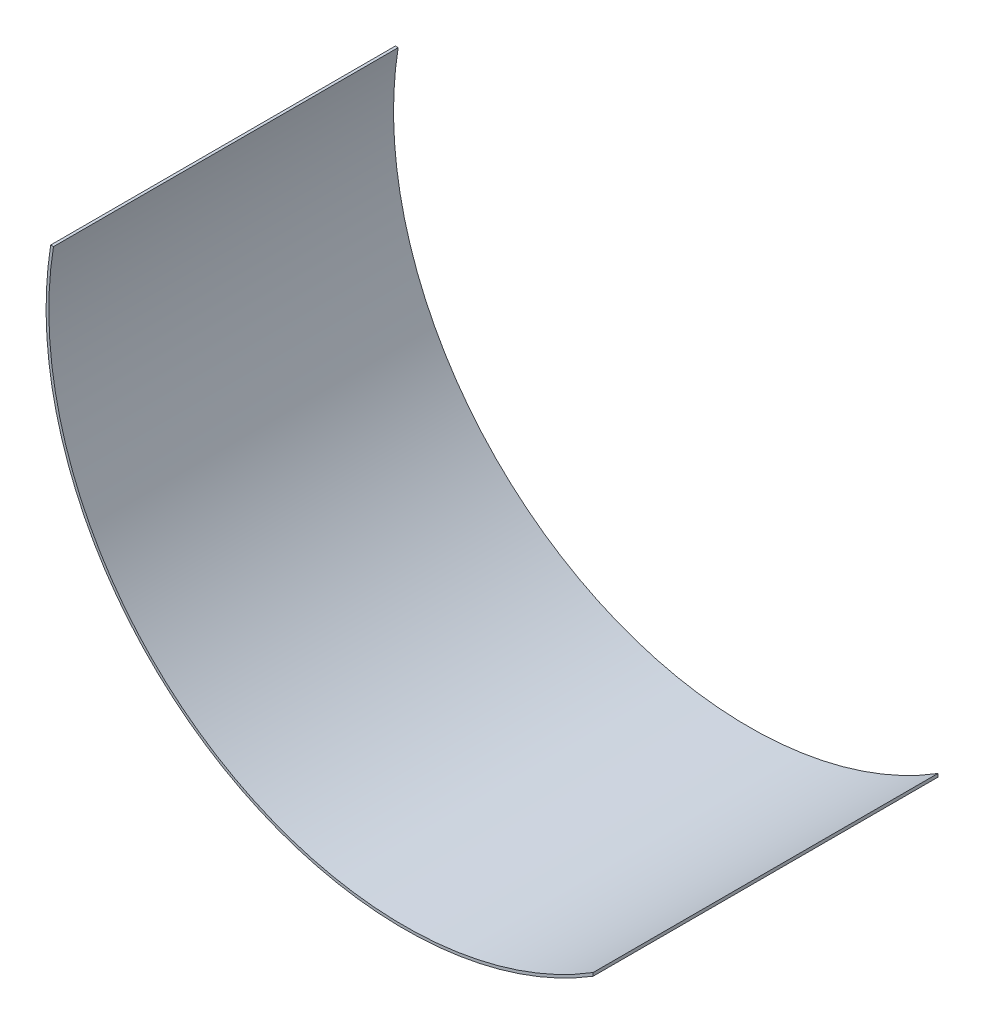
from build123d import *

# Parameters (mm, degrees)
SKETCH1_R           = 165.062282849
BOSS_EXTRUDE1_DEPTH = 158.75
SHELL1_T            = -1.27
SKETCH2_W           = 163.144728945
SKETCH2_H           = 394.61311295
CUT_EXTRUDE2_DEPTH  = 158.75
SKETCH3_W           = 362.622399732
SKETCH3_H           = 160.71006498
CUT_EXTRUDE3_DEPTH  = 158.75


with BuildPart() as part:
    # Sketch1 → Boss-Extrude1 (new body)
    with BuildSketch(Plane.XY):
        with Locations(Location((-31.532687059, 19.91445928, 0), (0, 0, 180))):
            Circle(SKETCH1_R)
    extrude(amount=BOSS_EXTRUDE1_DEPTH)

    # Shell1
    shell1_openings = [part.faces().sort_by_distance(p)[0] for p in [
        (-31.532687059, 19.91445928, 158.75),
        (-31.532687059, 19.91445928, 0),
    ]]
    offset(amount=SHELL1_T, openings=shell1_openings, kind=Kind.INTERSECTION)

    # Sketch2 → Cut-Extrude2 (cut)
    with BuildSketch(Plane.XY.offset(158.75)):
        with Locations((136.971926827, 42.916431228)):
            Rectangle(SKETCH2_W, SKETCH2_H)
    extrude(amount=-CUT_EXTRUDE2_DEPTH, mode=Mode.SUBTRACT)

    # Sketch3 → Cut-Extrude3 (cut)
    with BuildSketch(Plane.XY.offset(158.75)):
        with Locations((-34.997933009, 126.669881209)):
            Rectangle(SKETCH3_W, SKETCH3_H)
    extrude(amount=-CUT_EXTRUDE3_DEPTH, mode=Mode.SUBTRACT)


solid = part.part
